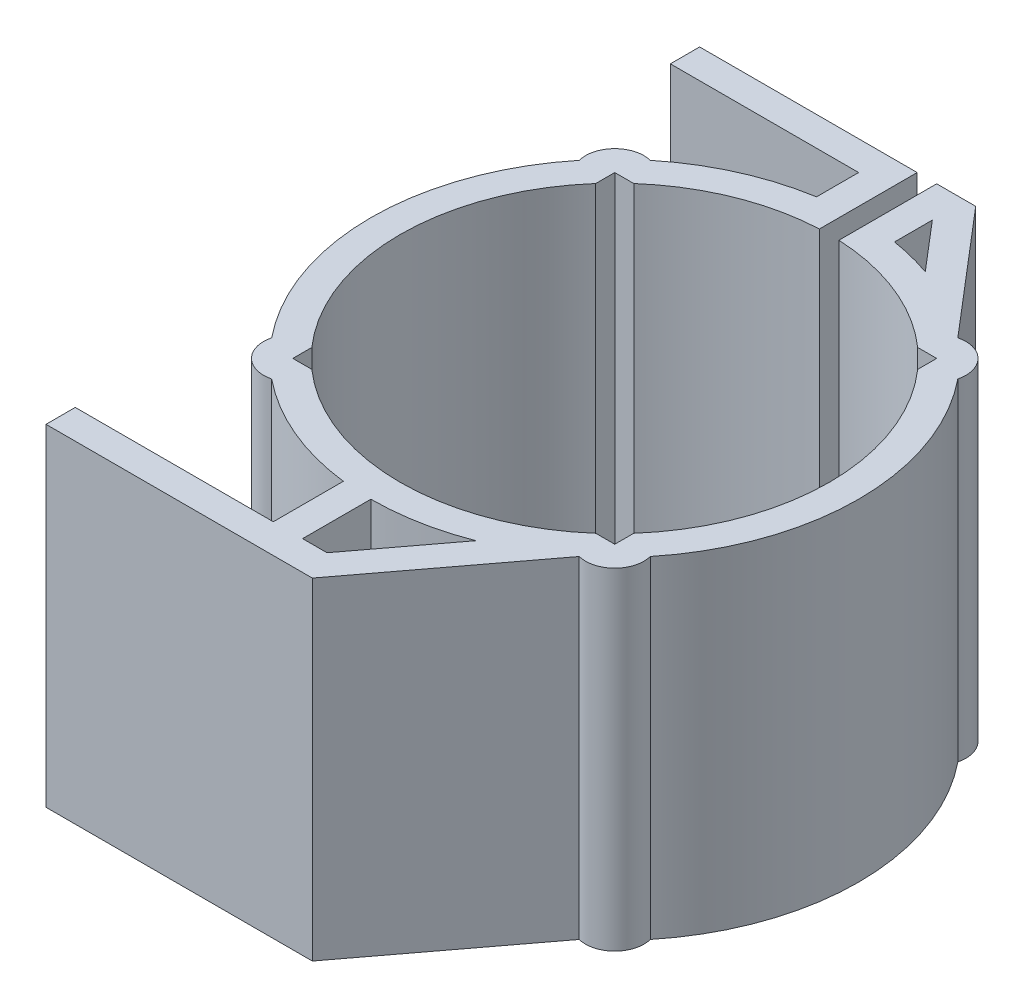
from build123d import *

# Parameters (mm, degrees)
BOSS_EXTRUDE1_DEPTH = 34
BOSS_EXTRUDE3_DEPTH = 12
CUT_EXTRUDE1_DEPTH  = 14.407172


with BuildPart() as part:
    # Sketch1 → Boss-Extrude1 (new body)
    with BuildSketch(Plane(origin=(0, 0, 0), x_dir=(1, 0, 0), z_dir=(0, 1, 0))):
        with BuildLine():
            Line((14.551632211, 16.5), (16.5, 16.5))
            Line((16.5, 16.5), (16.5, 14.551632211))
            ThreePointArc((16.5, 14.551632211), (22, 0), (16.5, -14.551632211))
            Line((16.5, -14.551632211), (16.5, -16.5))
            Line((16.5, -16.5), (14.551632211, -16.5))
            ThreePointArc((14.551632211, -16.5), (0, -22), (-14.551632211, -16.5))
            Line((-14.551632211, -16.5), (-16.5, -16.5))
            Line((-16.5, -16.5), (-16.5, -14.551632211))
            ThreePointArc((-16.5, -14.551632211), (-22, 0), (-16.5, 14.551632211))
            Line((-16.5, 14.551632211), (-16.5, 16.5))
            Line((-16.5, 16.5), (-14.551632211, 16.5))
            ThreePointArc((-14.551632211, 16.5), (-8.243992543, 20.396974946), (-1, 21.977260976))
            Line((-1, 21.977260976), (-1, 32))
            Line((-1, 32), (-23.299524673, 32))
            Line((-23.299524673, 32), (-23.299524673, 29))
            Line((-23.299524673, 29), (-4, 29))
            Line((-4, 29), (-4, 24.677925359))
            ThreePointArc((-4, 24.677925359), (-10.225195, 22.813272172), (-15.759494281, 19.407172386))
            ThreePointArc((-15.759494281, 19.407172386), (-18.621320344, 18.621320344), (-19.407172386, 15.759494281))
            ThreePointArc((-19.407172386, 15.759494281), (-25, 0), (-19.407172386, -15.759494281))
            ThreePointArc((-19.407172386, -15.759494281), (-18.621320344, -18.621320344), (-15.759494281, -19.407172386))
            ThreePointArc((-15.759494281, -19.407172386), (-9.7623033, -23.015156621), (-3, -24.819347292))
            Line((-3, -24.819347292), (-3, -32))
            Line((-3, -32), (-23.299524673, -32))
            Line((-23.299524673, -32), (-23.299524673, -35))
            Line((-23.299524673, -35), (4, -35))
            Line((4, -35), (15.759494281, -19.407172386))
            ThreePointArc((15.759494281, -19.407172386), (18.621320344, -18.621320344), (19.407172386, -15.759494281))
            ThreePointArc((19.407172386, -15.759494281), (25, 0), (19.407172386, 15.759494281))
            ThreePointArc((19.407172386, 15.759494281), (18.621320344, 18.621320344), (15.759494281, 19.407172386))
            Line((15.759494281, 19.407172386), (5, 32))
            Line((5, 32), (1, 32))
            Line((1, 32), (1, 21.977260976))
            ThreePointArc((1, 21.977260976), (8.243992543, 20.396974946), (14.551632211, 16.5))
        make_face()
        with BuildLine():
            ThreePointArc((0, -25), (4.613293609, -24.570663851), (9.068134921, -23.297401766))
            Line((9.068134921, -23.297401766), (2.504979303, -32))
            Line((2.504979303, -32), (0, -32))
            Line((0, -32), (0, -25))
        make_face(mode=Mode.SUBTRACT)
        with BuildLine():
            ThreePointArc((8.223751321, 23.608683026), (6.135213434, 24.235493725), (4, 24.677925359))
            Line((4, 24.677925359), (4, 28.552128404))
            Line((4, 28.552128404), (8.223751321, 23.608683026))
        make_face(mode=Mode.SUBTRACT)
    extrude(amount=BOSS_EXTRUDE1_DEPTH)

    # Sketch6 → Boss-Extrude3 (add)
    with BuildSketch(Plane(origin=(0, 23, 0), x_dir=(0, 0, -1), z_dir=(0, -1, 0))):
        Polygon((30.717367885, 3.963704263), (22.785433959, 3.963704263), (22.785433959, 10.604126234), align=None)
    extrude(amount=BOSS_EXTRUDE3_DEPTH)

    # Sketch3 → Cut-Extrude1 (cut)
    with BuildSketch(Plane.ZY.offset(-19.407172386)):
        with BuildLine():
            ThreePointArc((-23, 17), (-24.171572875, 19.828427125), (-27, 21))
            Line((-27, 21), (-27, 13))
            ThreePointArc((-27, 13), (-24.171572875, 14.171572875), (-23, 17))
        make_face()
        with BuildLine():
            Line((-27, 13), (-27, 21))
            ThreePointArc((-27, 21), (-31, 17), (-27, 13))
        make_face()
        with BuildLine():
            Line((-27, 21), (-32, 21))
            Line((-32, 21), (-32, 13))
            Line((-32, 13), (-27, 13))
            ThreePointArc((-27, 13), (-31, 17), (-27, 21))
        make_face()
    extrude(amount=CUT_EXTRUDE1_DEPTH, mode=Mode.SUBTRACT)


solid = part.part
